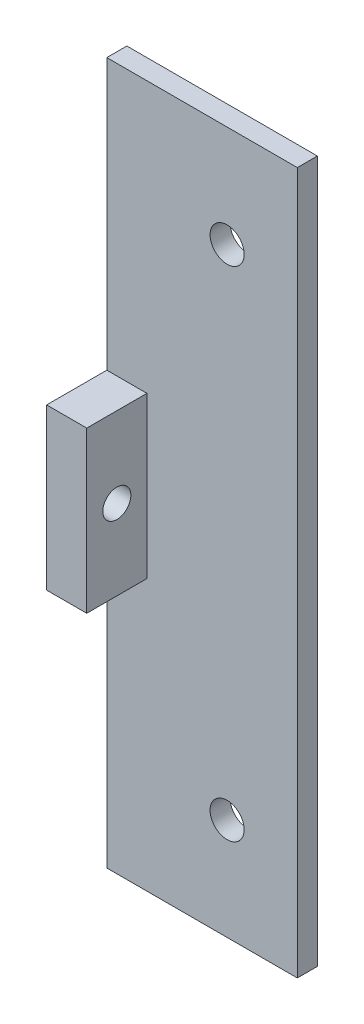
from build123d import *

# Parameters (mm, degrees)
ESQUISSE1_W             = 19
ESQUISSE1_H             = 70
ESQUISSE1_R             = 1.7
BOSS_EXTRU_1_DEPTH      = 2
ESQUISSE2_W             = 8
ESQUISSE2_H             = 16
BOSS_EXTRU_2_DEPTH      = 4
ESQUISSE3_R             = 1.4
ENL_V_MAT_EXTRU_1_DEPTH = 4


with BuildPart() as part:
    # Esquisse1 → Boss.-Extru.1 (new body)
    with BuildSketch(Plane.XY):
        with Locations((-2.5, -24.85)):
            Rectangle(ESQUISSE1_W, ESQUISSE1_H)
        Circle(ESQUISSE1_R, mode=Mode.SUBTRACT)
        with Locations((0, -49.7)):
            Circle(ESQUISSE1_R, mode=Mode.SUBTRACT)
    extrude(amount=BOSS_EXTRU_1_DEPTH)

    # Esquisse2 → Boss.-Extru.2 (add)
    with BuildSketch(Plane.ZY.offset(12)):
        with Locations((4, -24.85)):
            Rectangle(ESQUISSE2_W, ESQUISSE2_H)
    extrude(amount=-BOSS_EXTRU_2_DEPTH)

    # Esquisse3 → Enlèv. mat.-Extru.1 (cut)
    with BuildSketch(Plane.ZY.offset(12)):
        with Locations((5, -24.85)):
            Circle(ESQUISSE3_R)
    extrude(amount=-ENL_V_MAT_EXTRU_1_DEPTH, mode=Mode.SUBTRACT)


solid = part.part
